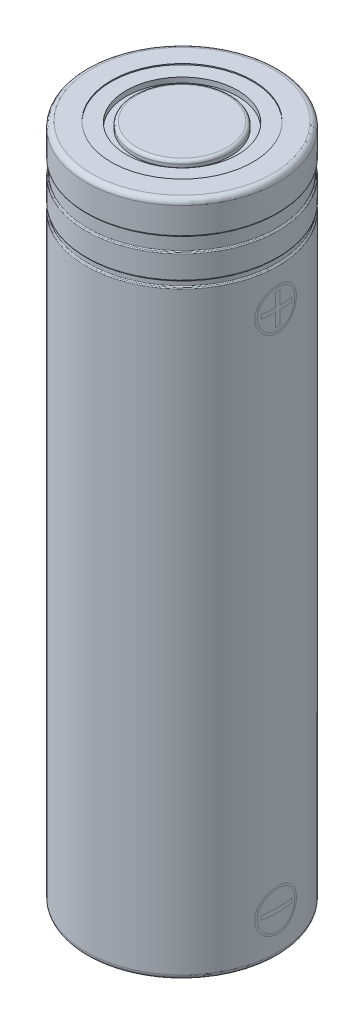
from build123d import *


with BuildPart() as part:
    # Sketch1 → Revolve1 (revolve)
    with BuildSketch(Plane.XY):
        with BuildLine():
            Line((7.4, 0.1), (7.9, 0.1))
            Line((7.9, 0.1), (8.7, 0.1))
            ThreePointArc((8.7, 0.1), (8.982842712, 0.217157288), (9.1, 0.5))
            Line((9.1, 0.5), (9.1, 57.54))
            ThreePointArc((9.1, 57.54), (8.998754845, 57.612466245), (8.96, 57.73078784))
            Line((8.96, 57.73078784), (8.96, 58.10921216))
            ThreePointArc((8.96, 58.10921216), (8.998754845, 58.227533755), (9.1, 58.3))
            Line((9.1, 58.3), (9.1, 60.46))
            ThreePointArc((9.1, 60.46), (8.998754845, 60.532466245), (8.96, 60.65078784))
            Line((8.96, 60.65078784), (8.96, 61.80921216))
            ThreePointArc((8.96, 61.80921216), (8.998754845, 61.927533755), (9.1, 62))
            Line((9.1, 62), (9.1, 64.5))
            ThreePointArc((9.1, 64.5), (8.982842712, 64.782842712), (8.7, 64.9))
            Line((8.7, 64.9), (6.8, 64.9))
            Line((6.8, 64.9), (5.35, 64.9))
            Line((5.35, 64.9), (5.35, 64.4))
            Line((5.35, 64.4), (4.63, 64.4))
            Line((4.63, 64.4), (4.63, 64.7))
            ThreePointArc((4.63, 64.7), (4.542132034, 64.912132034), (4.33, 65))
            Line((4.33, 65), (0, 65))
            Line((0, 65), (0, 0))
            Line((0, 0), (7.4, 0))
            Line((7.4, 0), (7.4, 0.1))
        make_face()
    revolve(axis=Axis((0, 0, 0), (0, -1, 0)))


with BuildPart() as body_2:
    # Sketch1_3 → Revolve2 (revolve)
    with BuildSketch(Plane.XY):
        with BuildLine():
            Line((9.2, 0.5), (9.2, 57.54))
            ThreePointArc((9.2, 57.54), (9.180622577, 57.599160798), (9.13, 57.63539392))
            ThreePointArc((9.13, 57.63539392), (9.079377423, 57.671627042), (9.06, 57.73078784))
            Line((9.06, 57.73078784), (9.06, 58.10921216))
            ThreePointArc((9.06, 58.10921216), (9.079377423, 58.168372958), (9.13, 58.20460608))
            ThreePointArc((9.13, 58.20460608), (9.180622577, 58.240839202), (9.2, 58.3))
            Line((9.2, 58.3), (9.2, 60.46))
            ThreePointArc((9.2, 60.46), (9.180622577, 60.519160798), (9.13, 60.55539392))
            ThreePointArc((9.13, 60.55539392), (9.079377423, 60.591627042), (9.06, 60.65078784))
            Line((9.06, 60.65078784), (9.06, 61.80921216))
            ThreePointArc((9.06, 61.80921216), (9.079377423, 61.868372958), (9.13, 61.90460608))
            ThreePointArc((9.13, 61.90460608), (9.180622577, 61.940839202), (9.2, 62))
            Line((9.2, 62), (9.2, 64.5))
            ThreePointArc((9.2, 64.5), (9.053553391, 64.853553391), (8.7, 65))
            Line((8.7, 65), (6.8, 65))
            Line((6.8, 65), (6.8, 64.9))
            Line((6.8, 64.9), (8.7, 64.9))
            ThreePointArc((8.7, 64.9), (8.982842712, 64.782842712), (9.1, 64.5))
            Line((9.1, 64.5), (9.1, 62))
            ThreePointArc((9.1, 62), (8.998754845, 61.927533755), (8.96, 61.80921216))
            Line((8.96, 61.80921216), (8.96, 60.65078784))
            ThreePointArc((8.96, 60.65078784), (8.998754845, 60.532466245), (9.1, 60.46))
            Line((9.1, 60.46), (9.1, 58.3))
            ThreePointArc((9.1, 58.3), (8.998754845, 58.227533755), (8.96, 58.10921216))
            Line((8.96, 58.10921216), (8.96, 57.73078784))
            ThreePointArc((8.96, 57.73078784), (8.998754845, 57.612466245), (9.1, 57.54))
            Line((9.1, 57.54), (9.1, 0.5))
            ThreePointArc((9.1, 0.5), (8.982842712, 0.217157288), (8.7, 0.1))
            Line((8.7, 0.1), (7.9, 0.1))
            Line((7.9, 0.1), (7.9, 0))
            Line((7.9, 0), (8.7, 0))
            ThreePointArc((8.7, 0), (9.053553391, 0.146446609), (9.2, 0.5))
        make_face()
    revolve(axis=Axis((0, 0, 0), (0, -1, 0)))


solid = Compound([part.part, body_2.part])
